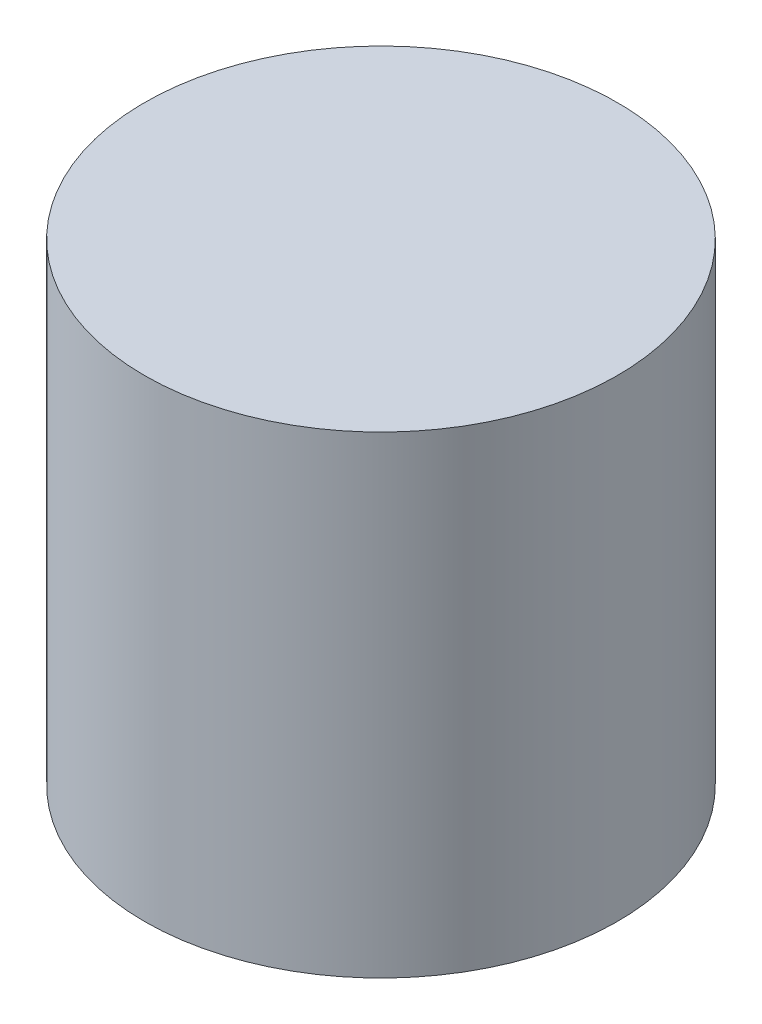
from build123d import *

# Parameters (mm, degrees)
CROQUIS1_R              = 3
SALIENTE_EXTRUIR1_DEPTH = 6


with BuildPart() as part:
    # Croquis1 → Saliente-Extruir1 (new body)
    with BuildSketch(Plane(origin=(0, 0, 0), x_dir=(1, 0, 0), z_dir=(0, 1, 0))):
        Circle(CROQUIS1_R)
    extrude(amount=SALIENTE_EXTRUIR1_DEPTH)


solid = part.part
